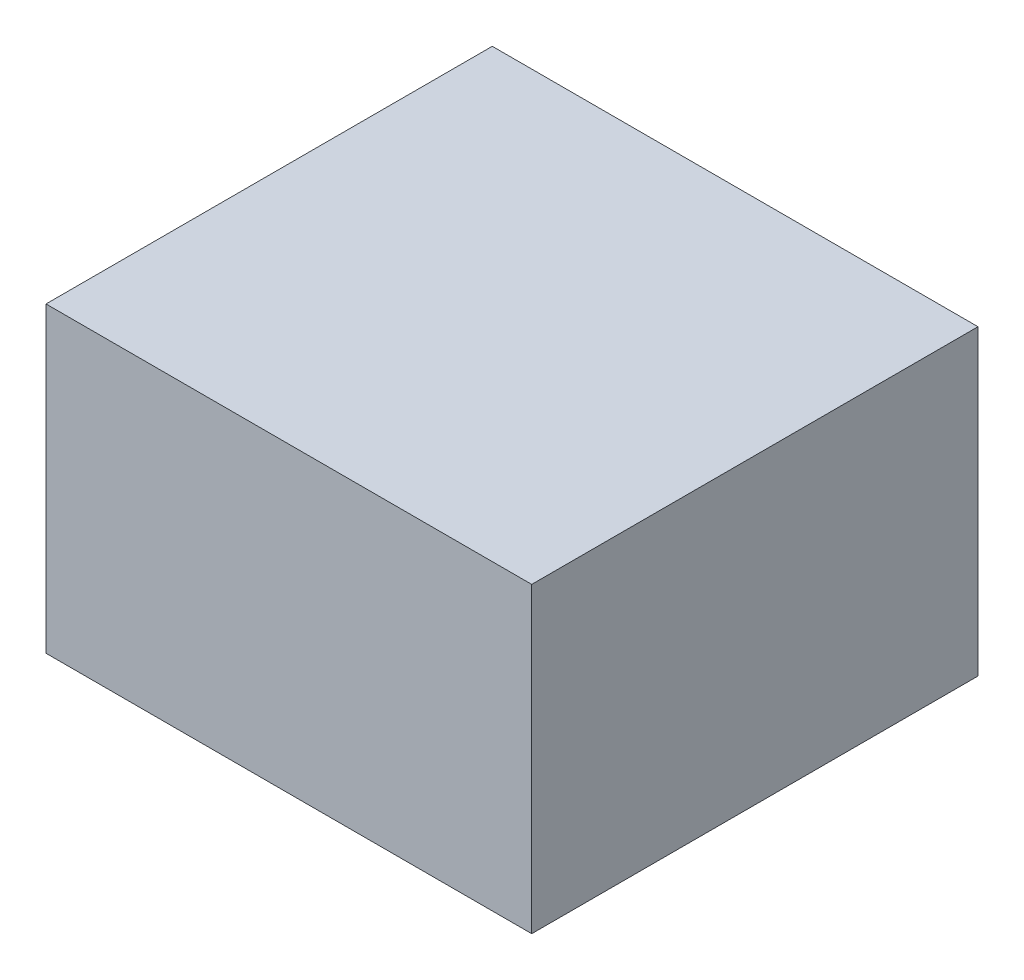
from build123d import *

# Parameters (mm, degrees)
SKETCH1_W           = 468
SKETCH1_H           = 430
BOSS_EXTRUDE1_DEPTH = 291.5


with BuildPart() as part:
    # Sketch1 → Boss-Extrude1 (new body)
    with BuildSketch(Plane(origin=(0, 0, 0), x_dir=(1, 0, 0), z_dir=(0, 1, 0))):
        with Locations((234, 215)):
            Rectangle(SKETCH1_W, SKETCH1_H)
    extrude(amount=BOSS_EXTRUDE1_DEPTH)


solid = part.part
